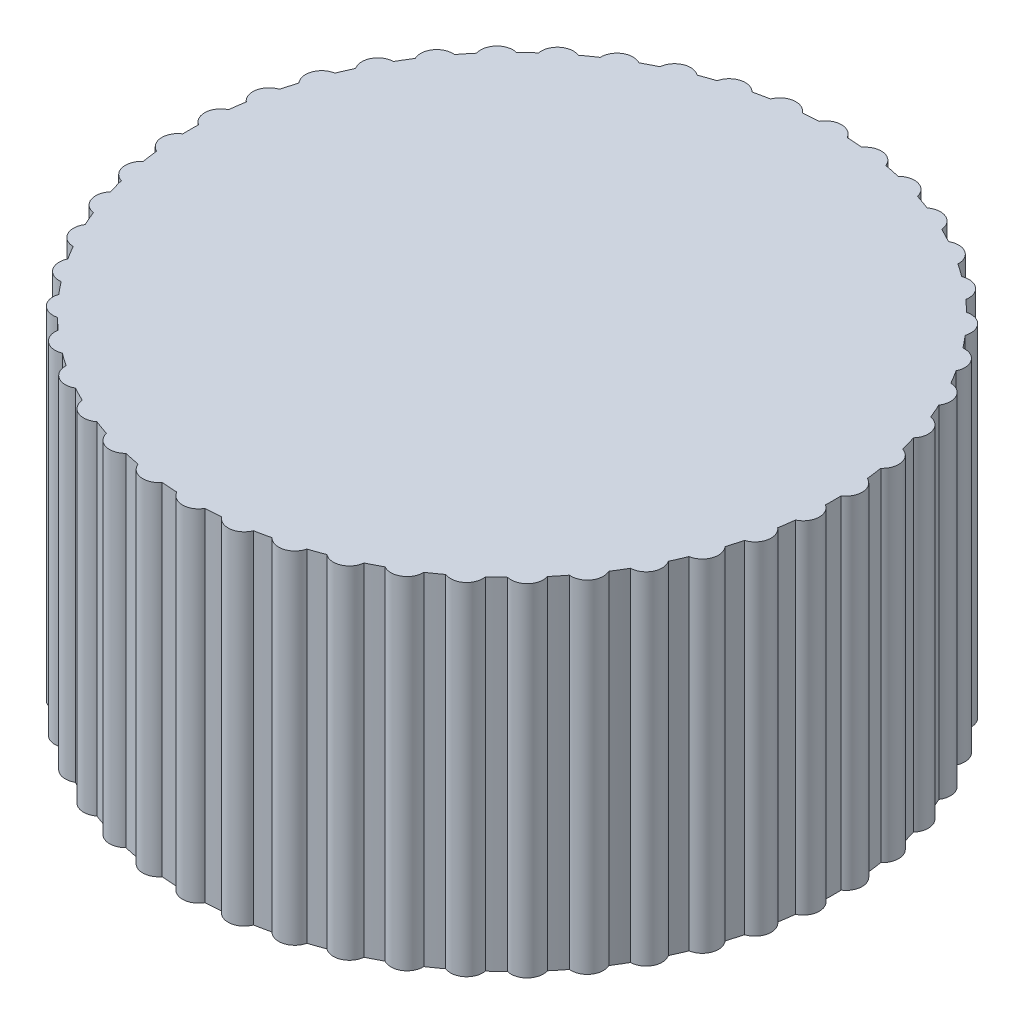
from build123d import *

# Parameters (mm, degrees)
SKETCH1_R           = 8
BOSS_EXTRUDE1_DEPTH = 4
SKETCH3_R           = 8
BOSS_EXTRUDE3_DEPTH = 4.5
SKETCH2_R           = 0.4
BOSS_EXTRUDE2_DEPTH = 8.5


with BuildPart() as part:
    # Sketch1 → Boss-Extrude1 (new body)
    with BuildSketch(Plane(origin=(0, 0, 0), x_dir=(1, 0, 0), z_dir=(0, 1, 0))):
        Circle(SKETCH1_R)
        Polygon((5.773502692, 0), (2.886751346, 5), (-2.886751346, 5), (-5.773502692, 0), (-2.886751346, -5), (2.886751346, -5), align=None, mode=Mode.SUBTRACT)
    extrude(amount=BOSS_EXTRUDE1_DEPTH)

    # Sketch3 → Boss-Extrude3 (add)
    with BuildSketch(Plane(origin=(0, 4, 0), x_dir=(1, 0, 0), z_dir=(0, 1, 0))):
        Circle(SKETCH3_R)
    extrude(amount=BOSS_EXTRUDE3_DEPTH)

    # Sketch2 → Boss-Extrude2 (add, through all)
    with BuildSketch(Plane(origin=(0, 8.5, 0), x_dir=(1, 0, 0), z_dir=(0, 1, 0))):
        with Locations((0, 7.8)):
            Circle(SKETCH2_R)
        with Locations((1.062099863, 7.727350379)):
            Circle(SKETCH2_R)
        with Locations((2.104414815, 7.510754841)):
            Circle(SKETCH2_R)
        with Locations((3.107528501, 7.154248152)):
            Circle(SKETCH2_R)
        with Locations((4.05275481, 6.664471355)):
            Circle(SKETCH2_R)
        with Locations((4.922485966, 6.050548067)):
            Circle(SKETCH2_R)
        with Locations((5.700520521, 5.323914517)):
            Circle(SKETCH2_R)
        with Locations((6.372365165, 4.498106512)):
            Circle(SKETCH2_R)
        with Locations((6.925504704, 3.588507294)):
            Circle(SKETCH2_R)
        with Locations((7.349635193, 2.612060975)):
            Circle(SKETCH2_R)
        with Locations((7.636855884, 1.586956902)):
            Circle(SKETCH2_R)
        with Locations((7.7818164, 0.532290824)):
            Circle(SKETCH2_R)
        with Locations((7.7818164, -0.532290824)):
            Circle(SKETCH2_R)
        with Locations((7.636855884, -1.586956902)):
            Circle(SKETCH2_R)
        with Locations((7.349635193, -2.612060975)):
            Circle(SKETCH2_R)
        with Locations((6.925504704, -3.588507294)):
            Circle(SKETCH2_R)
        with Locations((6.372365165, -4.498106512)):
            Circle(SKETCH2_R)
        with Locations((5.700520521, -5.323914517)):
            Circle(SKETCH2_R)
        with Locations((4.922485966, -6.050548067)):
            Circle(SKETCH2_R)
        with Locations((4.05275481, -6.664471355)):
            Circle(SKETCH2_R)
        with Locations((3.107528501, -7.154248152)):
            Circle(SKETCH2_R)
        with Locations((2.104414815, -7.510754841)):
            Circle(SKETCH2_R)
        with Locations((1.062099863, -7.727350379)):
            Circle(SKETCH2_R)
        with Locations((0, -7.8)):
            Circle(SKETCH2_R)
        with Locations((-1.062099863, -7.727350379)):
            Circle(SKETCH2_R)
        with Locations((-2.104414815, -7.510754841)):
            Circle(SKETCH2_R)
        with Locations((-3.107528501, -7.154248152)):
            Circle(SKETCH2_R)
        with Locations((-4.05275481, -6.664471355)):
            Circle(SKETCH2_R)
        with Locations((-4.922485966, -6.050548067)):
            Circle(SKETCH2_R)
        with Locations((-5.700520521, -5.323914517)):
            Circle(SKETCH2_R)
        with Locations((-6.372365165, -4.498106512)):
            Circle(SKETCH2_R)
        with Locations((-6.925504704, -3.588507294)):
            Circle(SKETCH2_R)
        with Locations((-7.349635193, -2.612060975)):
            Circle(SKETCH2_R)
        with Locations((-7.636855884, -1.586956902)):
            Circle(SKETCH2_R)
        with Locations((-7.7818164, -0.532290824)):
            Circle(SKETCH2_R)
        with Locations((-7.7818164, 0.532290824)):
            Circle(SKETCH2_R)
        with Locations((-7.636855884, 1.586956902)):
            Circle(SKETCH2_R)
        with Locations((-7.349635193, 2.612060975)):
            Circle(SKETCH2_R)
        with Locations((-6.925504704, 3.588507294)):
            Circle(SKETCH2_R)
        with Locations((-6.372365165, 4.498106512)):
            Circle(SKETCH2_R)
        with Locations((-5.700520521, 5.323914517)):
            Circle(SKETCH2_R)
        with Locations((-4.922485966, 6.050548067)):
            Circle(SKETCH2_R)
        with Locations((-4.05275481, 6.664471355)):
            Circle(SKETCH2_R)
        with Locations((-3.107528501, 7.154248152)):
            Circle(SKETCH2_R)
        with Locations((-2.104414815, 7.510754841)):
            Circle(SKETCH2_R)
        with Locations((-1.062099863, 7.727350379)):
            Circle(SKETCH2_R)
    extrude(amount=-BOSS_EXTRUDE2_DEPTH)


solid = part.part
